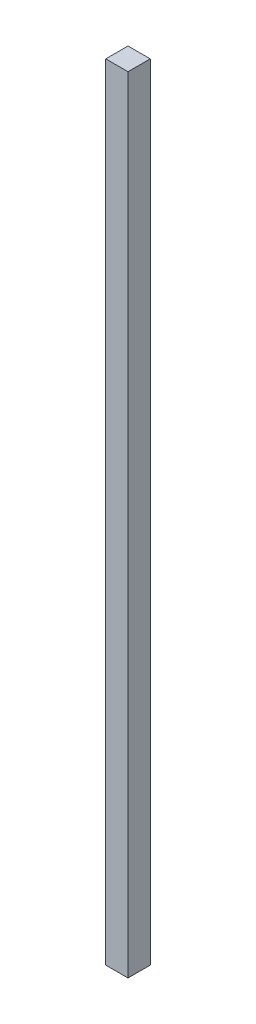
from build123d import *

# Parameters (mm, degrees)
SKETCH_1_W      = 5
SKETCH_1_H      = 5
EXTRUDE_1_DEPTH = 176.37


with BuildPart() as part:
    # Эскиз1 → Бобышка-Вытянуть1 (new body)
    with BuildSketch(Plane(origin=(0, 0, 0), x_dir=(1, 0, 0), z_dir=(0, 1, 0))):
        Rectangle(SKETCH_1_W, SKETCH_1_H)
    extrude(amount=EXTRUDE_1_DEPTH)


solid = part.part
